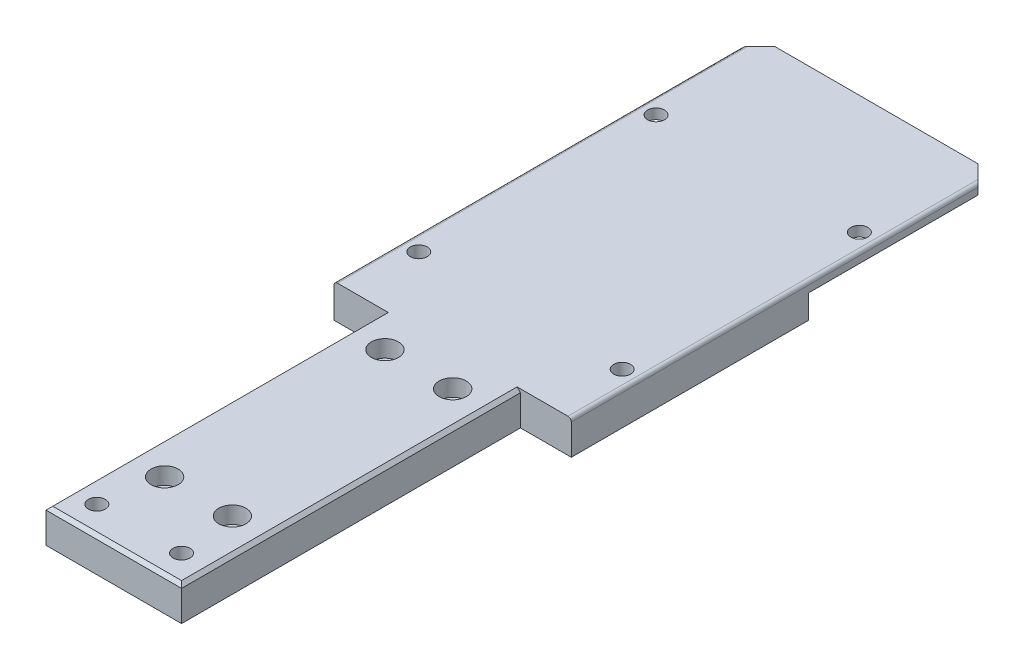
from build123d import *

# Parameters (mm, degrees)
BOSS_EXTRUDE1_DEPTH = 10
CUT_EXTRUDE1_DEPTH  = 7
SKETCH4_R           = 4
CUT_EXTRUDE2_DEPTH  = 5
SKETCH5_R           = 2.5
CUT_EXTRUDE3_DEPTH  = 6
SKETCH6_R           = 2.5
CUT_EXTRUDE4_DEPTH  = 11
SKETCH7_R           = 2.5
CUT_EXTRUDE5_DEPTH  = 11
CHAMFER1_SIZE       = 1
FILLET1_R           = 1


with BuildPart() as part:
    # Sketch2 → Boss-Extrude1 (new body)
    with BuildSketch(Plane(origin=(0, 0, 0), x_dir=(1, 0, 0), z_dir=(0, 1, 0))):
        Polygon((0, 0), (40, 0), (40, 100), (55, 100), (55, 220), (50, 225), (-10, 225), (-15, 220), (-15, 100), (0, 100), align=None)
    extrude(amount=BOSS_EXTRUDE1_DEPTH)

    # Sketch3 → Cut-Extrude1 (cut)
    with BuildSketch(Plane.XZ):
        Polygon((-15, -220), (-10, -225), (50, -225), (55, -220), (55, -170), (-15, -170), align=None)
    extrude(amount=-CUT_EXTRUDE1_DEPTH, mode=Mode.SUBTRACT)

    # Sketch4 → Cut-Extrude2 (cut)
    with BuildSketch(Plane(origin=(0, 10, 0), x_dir=(1, 0, 0), z_dir=(0, 1, 0))):
        with Locations((10, 25)):
            Circle(SKETCH4_R)
        with Locations((30, 25)):
            Circle(SKETCH4_R)
        with Locations((10, 90)):
            Circle(SKETCH4_R)
        with Locations((30, 90)):
            Circle(SKETCH4_R)
    extrude(amount=-CUT_EXTRUDE2_DEPTH, mode=Mode.SUBTRACT)

    # Sketch5 → Cut-Extrude3 (cut, through all)
    with BuildSketch(Plane(origin=(0, 5, 0), x_dir=(1, 0, 0), z_dir=(0, 1, 0))):
        with Locations((30, 90)):
            Circle(SKETCH5_R)
        with Locations((10, 90)):
            Circle(SKETCH5_R)
        with Locations((10, 25)):
            Circle(SKETCH5_R)
        with Locations((30, 25)):
            Circle(SKETCH5_R)
    extrude(amount=-CUT_EXTRUDE3_DEPTH, mode=Mode.SUBTRACT)

    # Sketch6 → Cut-Extrude4 (cut, through all)
    with BuildSketch(Plane(origin=(0, 10, 0), x_dir=(1, 0, 0), z_dir=(0, 1, 0))):
        with Locations((50, 190)):
            Circle(SKETCH6_R)
        with Locations((-10, 190)):
            Circle(SKETCH6_R)
        with Locations((-10, 120)):
            Circle(SKETCH6_R)
        with Locations((50, 120)):
            Circle(SKETCH6_R)
    extrude(amount=-CUT_EXTRUDE4_DEPTH, mode=Mode.SUBTRACT)

    # Sketch7 → Cut-Extrude5 (cut, through all)
    with BuildSketch(Plane(origin=(0, 10, 0), x_dir=(1, 0, 0), z_dir=(0, 1, 0))):
        with Locations((32, 8)):
            Circle(SKETCH7_R)
        with Locations((7.000002149, 8.010365644)):
            Circle(SKETCH7_R)
    extrude(amount=-CUT_EXTRUDE5_DEPTH, mode=Mode.SUBTRACT)

    # Chamfer1
    chamfer1_edges = [part.edges().sort_by_distance(p)[0] for p in [
        (40, 10, -50),
        (0, 10, -50),
        (20, 10, 0),
    ]]
    chamfer(chamfer1_edges, length=CHAMFER1_SIZE)

    # Fillet1
    fillet1_edges = [part.edges().sort_by_distance(p)[0] for p in [
        (55, 10, -160),
        (-15, 10, -160),
    ]]
    fillet(fillet1_edges, radius=FILLET1_R)


solid = part.part
